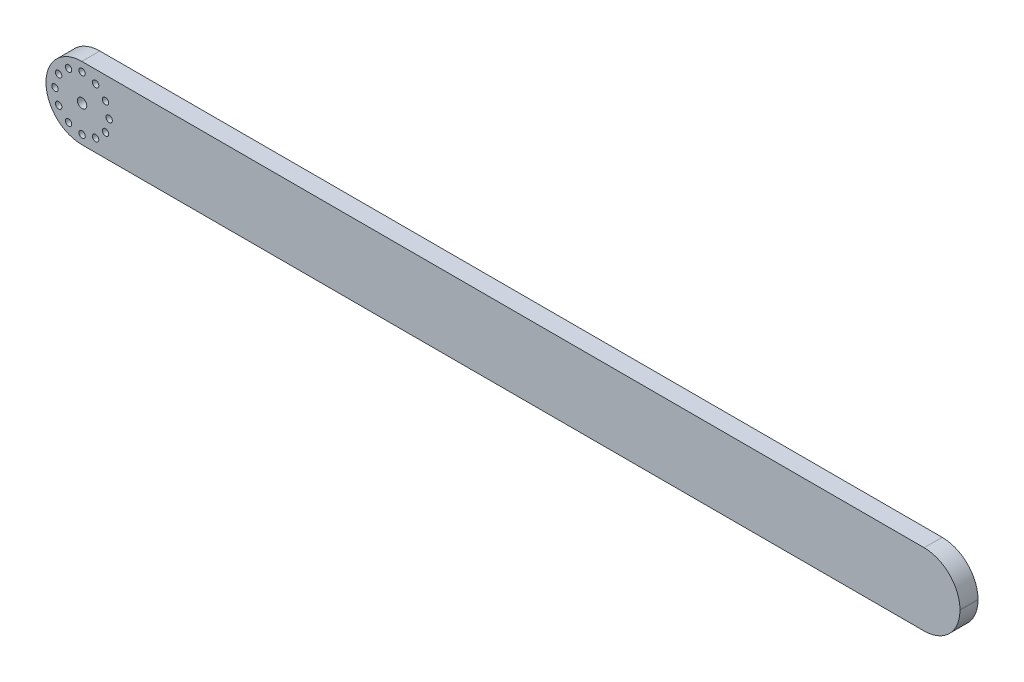
from build123d import *

# Parameters (mm, degrees)
BOSS_EXTRUDE1_DEPTH = 19.05
SKETCH3_R           = 16.66875
CUT_EXTRUDE1_DEPTH  = 9.525
SKETCH5_R           = 4.9609375
SKETCH5_R_2         = 3.3734375
CUT_EXTRUDE10_DEPTH = 19.05


with BuildPart() as part:
    # Sketch2 → Boss-Extrude1 (new body)
    with BuildSketch(Plane.XY):
        with BuildLine():
            Line((37.846, 0), (927.354, 0))
            ThreePointArc((927.354, 0), (954.115163241, -11.084836759), (965.2, -37.846))
            Line((965.2, -37.846), (965.2, -38.354))
            ThreePointArc((965.2, -38.354), (954.115163241, -65.115163241), (927.354, -76.2))
            Line((927.354, -76.2), (37.846, -76.2))
            ThreePointArc((37.846, -76.2), (11.084836759, -65.115163241), (0, -38.354))
            Line((0, -38.354), (0, -37.846))
            ThreePointArc((0, -37.846), (11.084836759, -11.084836759), (37.846, 0))
        make_face()
    extrude(amount=BOSS_EXTRUDE1_DEPTH)

    # Sketch3 → Cut-Extrude1 (cut)
    with BuildSketch(Plane.XY):
        with Locations((120.65, -38.1)):
            Circle(SKETCH3_R)
        with Locations((241.3, -38.1)):
            Circle(SKETCH3_R)
        with Locations((361.95, -38.1)):
            Circle(SKETCH3_R)
        with Locations((844.55, -38.1)):
            Circle(SKETCH3_R)
        with Locations((723.9, -38.1)):
            Circle(SKETCH3_R)
        with Locations((603.25, -38.1)):
            Circle(SKETCH3_R)
        with Locations((482.6, -38.1)):
            Circle(SKETCH3_R)
    extrude(amount=CUT_EXTRUDE1_DEPTH, mode=Mode.SUBTRACT)

    # Sketch5 → Cut-Extrude10 (cut)
    with BuildSketch(Plane.XY):
        with Locations((38.1, -38.1)):
            Circle(SKETCH5_R)
        with Locations((66.675, -38.1)):
            Circle(SKETCH5_R_2)
        with Locations((62.846675913, -52.3875)):
            Circle(SKETCH5_R_2)
        with Locations((52.3875, -62.846675913)):
            Circle(SKETCH5_R_2)
        with Locations((38.1, -66.675)):
            Circle(SKETCH5_R_2)
        with Locations((23.8125, -62.846675913)):
            Circle(SKETCH5_R_2)
        with Locations((13.353324087, -52.3875)):
            Circle(SKETCH5_R_2)
        with Locations((9.525, -38.1)):
            Circle(SKETCH5_R_2)
        with Locations((13.353324087, -23.8125)):
            Circle(SKETCH5_R_2)
        with Locations((23.8125, -13.353324087)):
            Circle(SKETCH5_R_2)
        with Locations((38.1, -9.525)):
            Circle(SKETCH5_R_2)
        with Locations((52.3875, -13.353324087)):
            Circle(SKETCH5_R_2)
        with Locations((62.846675913, -23.8125)):
            Circle(SKETCH5_R_2)
    extrude(amount=CUT_EXTRUDE10_DEPTH, mode=Mode.SUBTRACT)


solid = part.part
